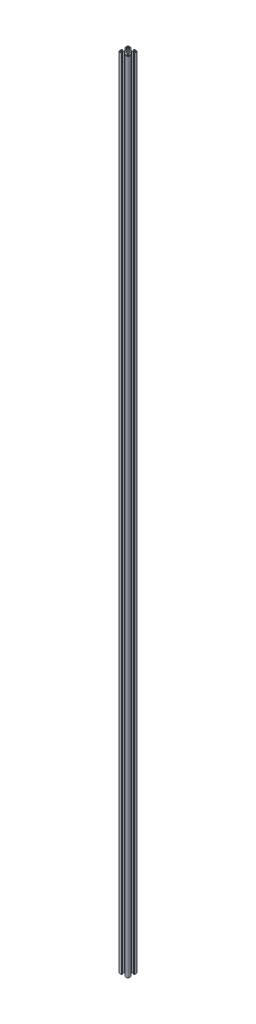
from build123d import *

# Parameters (mm, degrees)
SKETCH_3_R      = 3.4
EXTRUDE_1_DEPTH = 2477.2


with BuildPart() as part:
    # 草图3 → 凸台-拉伸1 (new body)
    with BuildSketch(Plane(origin=(0, 0, 0), x_dir=(1, 0, 0), z_dir=(0, 1, 0))):
        with BuildLine():
            Line((-15, -12.5), (-15, -5.4))
            ThreePointArc((-15, -5.4), (-14.941421356, -5.258578644), (-14.8, -5.2))
            Line((-14.8, -5.2), (-14.4, -5.2))
            ThreePointArc((-14.4, -5.2), (-14.258578644, -5.141421356), (-14.2, -5))
            Line((-14.2, -5), (-14.2, -4.3))
            ThreePointArc((-14.2, -4.3), (-14.141421356, -4.158578644), (-14, -4.1))
            Line((-14, -4.1), (-13.2, -4.1))
            Line((-13.2, -4.1), (-13.2, -8.25))
            Line((-13.2, -8.25), (-9.522792206, -8.25))
            Line((-9.522792206, -8.25), (-5.8, -4.527207794))
            Line((-5.8, -4.527207794), (-5.8, 4.527207794))
            Line((-5.8, 4.527207794), (-9.522792206, 8.25))
            Line((-9.522792206, 8.25), (-13.2, 8.25))
            Line((-13.2, 8.25), (-13.2, 4.1))
            Line((-13.2, 4.1), (-14, 4.1))
            ThreePointArc((-14, 4.1), (-14.141421356, 4.158578644), (-14.2, 4.3))
            Line((-14.2, 4.3), (-14.2, 5))
            ThreePointArc((-14.2, 5), (-14.258578644, 5.141421356), (-14.4, 5.2))
            Line((-14.4, 5.2), (-14.8, 5.2))
            ThreePointArc((-14.8, 5.2), (-14.941421356, 5.258578644), (-15, 5.4))
            Line((-15, 5.4), (-15, 12.5))
            ThreePointArc((-15, 12.5), (-14.267766953, 14.267766953), (-12.5, 15))
            Line((-12.5, 15), (-5.4, 15))
            ThreePointArc((-5.4, 15), (-5.258578644, 14.941421356), (-5.2, 14.8))
            Line((-5.2, 14.8), (-5.2, 14.4))
            ThreePointArc((-5.2, 14.4), (-5.141421356, 14.258578644), (-5, 14.2))
            Line((-5, 14.2), (-4.3, 14.2))
            ThreePointArc((-4.3, 14.2), (-4.158578644, 14.141421356), (-4.1, 14))
            Line((-4.1, 14), (-4.1, 13.2))
            Line((-4.1, 13.2), (-8.25, 13.2))
            Line((-8.25, 13.2), (-8.25, 9.522792206))
            Line((-8.25, 9.522792206), (-4.527207794, 5.8))
            Line((-4.527207794, 5.8), (4.527207794, 5.8))
            Line((4.527207794, 5.8), (8.25, 9.522792206))
            Line((8.25, 9.522792206), (8.25, 13.2))
            Line((8.25, 13.2), (4.1, 13.2))
            Line((4.1, 13.2), (4.1, 14))
            ThreePointArc((4.1, 14), (4.158578644, 14.141421356), (4.3, 14.2))
            Line((4.3, 14.2), (5, 14.2))
            ThreePointArc((5, 14.2), (5.141421356, 14.258578644), (5.2, 14.4))
            Line((5.2, 14.4), (5.2, 14.8))
            ThreePointArc((5.2, 14.8), (5.258578644, 14.941421356), (5.4, 15))
            Line((5.4, 15), (12.5, 15))
            ThreePointArc((12.5, 15), (14.267766953, 14.267766953), (15, 12.5))
            Line((15, 12.5), (15, 5.4))
            ThreePointArc((15, 5.4), (14.941421356, 5.258578644), (14.8, 5.2))
            Line((14.8, 5.2), (14.4, 5.2))
            ThreePointArc((14.4, 5.2), (14.258578644, 5.141421356), (14.2, 5))
            Line((14.2, 5), (14.2, 4.3))
            ThreePointArc((14.2, 4.3), (14.141421356, 4.158578644), (14, 4.1))
            Line((14, 4.1), (13.2, 4.1))
            Line((13.2, 4.1), (13.2, 8.25))
            Line((13.2, 8.25), (9.522792206, 8.25))
            Line((9.522792206, 8.25), (5.8, 4.527207794))
            Line((5.8, 4.527207794), (5.8, -4.527207794))
            Line((5.8, -4.527207794), (9.522792206, -8.25))
            Line((9.522792206, -8.25), (13.2, -8.25))
            Line((13.2, -8.25), (13.2, -4.1))
            Line((13.2, -4.1), (14, -4.1))
            ThreePointArc((14, -4.1), (14.141421356, -4.158578644), (14.2, -4.3))
            Line((14.2, -4.3), (14.2, -5))
            ThreePointArc((14.2, -5), (14.258578644, -5.141421356), (14.4, -5.2))
            Line((14.4, -5.2), (14.8, -5.2))
            ThreePointArc((14.8, -5.2), (14.941421356, -5.258578644), (15, -5.4))
            Line((15, -5.4), (15, -12.5))
            ThreePointArc((15, -12.5), (14.267766953, -14.267766953), (12.5, -15))
            Line((12.5, -15), (5.4, -15))
            ThreePointArc((5.4, -15), (5.258578644, -14.941421356), (5.2, -14.8))
            Line((5.2, -14.8), (5.2, -14.4))
            ThreePointArc((5.2, -14.4), (5.141421356, -14.258578644), (5, -14.2))
            Line((5, -14.2), (4.3, -14.2))
            ThreePointArc((4.3, -14.2), (4.158578644, -14.141421356), (4.1, -14))
            Line((4.1, -14), (4.1, -13.2))
            Line((4.1, -13.2), (8.25, -13.2))
            Line((8.25, -13.2), (8.25, -9.522792206))
            Line((8.25, -9.522792206), (4.527207794, -5.8))
            Line((4.527207794, -5.8), (-4.527207794, -5.8))
            Line((-4.527207794, -5.8), (-8.25, -9.522792206))
            Line((-8.25, -9.522792206), (-8.25, -13.2))
            Line((-8.25, -13.2), (-4.1, -13.2))
            Line((-4.1, -13.2), (-4.1, -14))
            ThreePointArc((-4.1, -14), (-4.158578644, -14.141421356), (-4.3, -14.2))
            Line((-4.3, -14.2), (-5, -14.2))
            ThreePointArc((-5, -14.2), (-5.141421356, -14.258578644), (-5.2, -14.4))
            Line((-5.2, -14.4), (-5.2, -14.8))
            ThreePointArc((-5.2, -14.8), (-5.258578644, -14.941421356), (-5.4, -15))
            Line((-5.4, -15), (-12.5, -15))
            ThreePointArc((-12.5, -15), (-14.267766953, -14.267766953), (-15, -12.5))
        make_face()
        Circle(SKETCH_3_R, mode=Mode.SUBTRACT)
        with BuildLine():
            Line((-13.2, -12.2), (-13.2, -11.05))
            ThreePointArc((-13.2, -11.05), (-12.907106781, -10.342893219), (-12.2, -10.05))
            Line((-12.2, -10.05), (-11.05, -10.05))
            ThreePointArc((-11.05, -10.05), (-10.342893219, -10.342893219), (-10.05, -11.05))
            Line((-10.05, -11.05), (-10.05, -12.2))
            ThreePointArc((-10.05, -12.2), (-10.342893219, -12.907106781), (-11.05, -13.2))
            Line((-11.05, -13.2), (-12.2, -13.2))
            ThreePointArc((-12.2, -13.2), (-12.907106781, -12.907106781), (-13.2, -12.2))
        make_face(mode=Mode.SUBTRACT)
        with BuildLine():
            Line((-10.05, 12.2), (-10.05, 11.05))
            ThreePointArc((-10.05, 11.05), (-10.342893219, 10.342893219), (-11.05, 10.05))
            Line((-11.05, 10.05), (-12.2, 10.05))
            ThreePointArc((-12.2, 10.05), (-12.907106781, 10.342893219), (-13.2, 11.05))
            Line((-13.2, 11.05), (-13.2, 12.2))
            ThreePointArc((-13.2, 12.2), (-12.907106781, 12.907106781), (-12.2, 13.2))
            Line((-12.2, 13.2), (-11.05, 13.2))
            ThreePointArc((-11.05, 13.2), (-10.342893219, 12.907106781), (-10.05, 12.2))
        make_face(mode=Mode.SUBTRACT)
        with BuildLine():
            Line((13.2, 12.2), (13.2, 11.05))
            ThreePointArc((13.2, 11.05), (12.907106781, 10.342893219), (12.2, 10.05))
            Line((12.2, 10.05), (11.05, 10.05))
            ThreePointArc((11.05, 10.05), (10.342893219, 10.342893219), (10.05, 11.05))
            Line((10.05, 11.05), (10.05, 12.2))
            ThreePointArc((10.05, 12.2), (10.342893219, 12.907106781), (11.05, 13.2))
            Line((11.05, 13.2), (12.2, 13.2))
            ThreePointArc((12.2, 13.2), (12.907106781, 12.907106781), (13.2, 12.2))
        make_face(mode=Mode.SUBTRACT)
        with BuildLine():
            Line((10.05, -12.2), (10.05, -11.05))
            ThreePointArc((10.05, -11.05), (10.342893219, -10.342893219), (11.05, -10.05))
            Line((11.05, -10.05), (12.2, -10.05))
            ThreePointArc((12.2, -10.05), (12.907106781, -10.342893219), (13.2, -11.05))
            Line((13.2, -11.05), (13.2, -12.2))
            ThreePointArc((13.2, -12.2), (12.907106781, -12.907106781), (12.2, -13.2))
            Line((12.2, -13.2), (11.05, -13.2))
            ThreePointArc((11.05, -13.2), (10.342893219, -12.907106781), (10.05, -12.2))
        make_face(mode=Mode.SUBTRACT)
    extrude(amount=EXTRUDE_1_DEPTH)


solid = part.part
